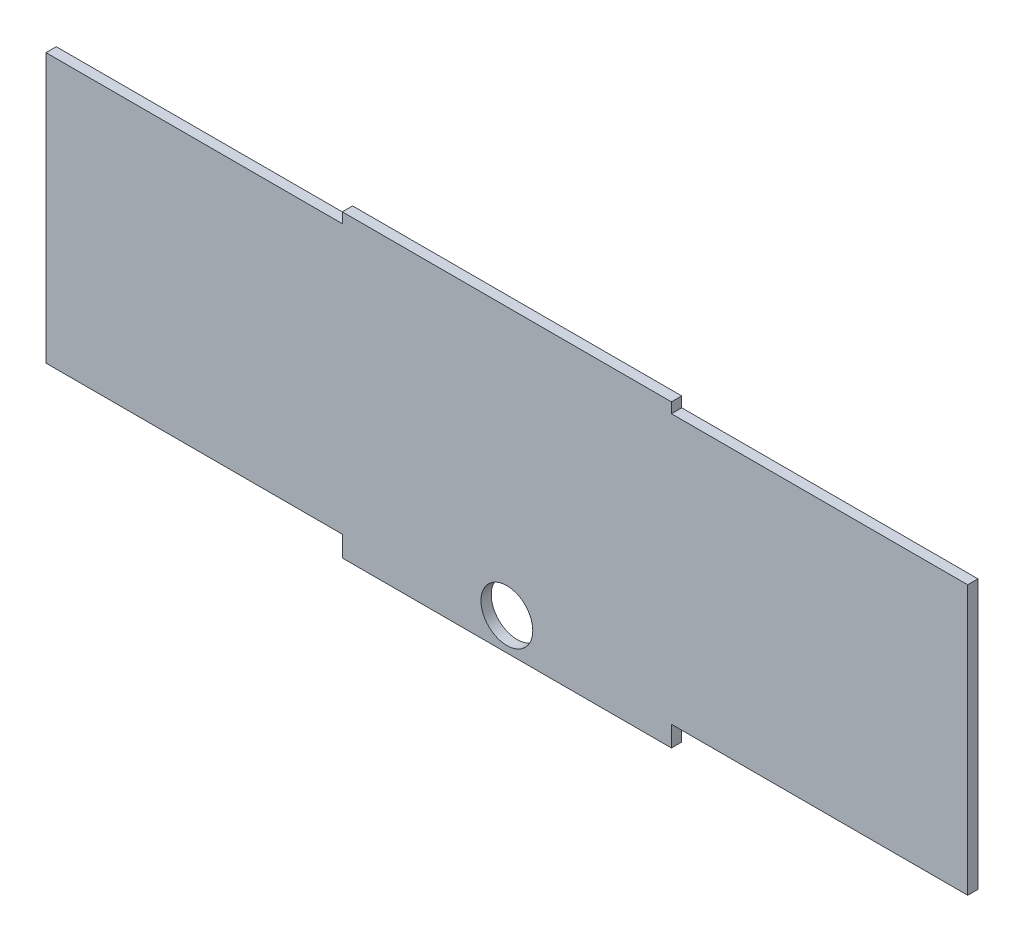
from build123d import *

# Parameters (mm, degrees)
SKETCH1_R           = 4
BOSS_EXTRUDE1_DEPTH = 0.79375


with BuildPart() as part:
    # Sketch1 → Boss-Extrude1 (new body, symmetric)
    with BuildSketch(Plane.XY):
        Polygon((25.4, -23.925), (25.4, -20.75), (71.12, -20.75), (71.12, 20.75), (25.4, 20.75), (25.4, 22.3375), (-25.4, 22.3375), (-25.4, 20.75), (-71.12, 20.75), (-71.12, -20.75), (-25.4, -20.75), (-25.4, -23.925), align=None)
        with Locations((0, -18.925)):
            Circle(SKETCH1_R, mode=Mode.SUBTRACT)
    extrude(amount=BOSS_EXTRUDE1_DEPTH, both=True)


solid = part.part
